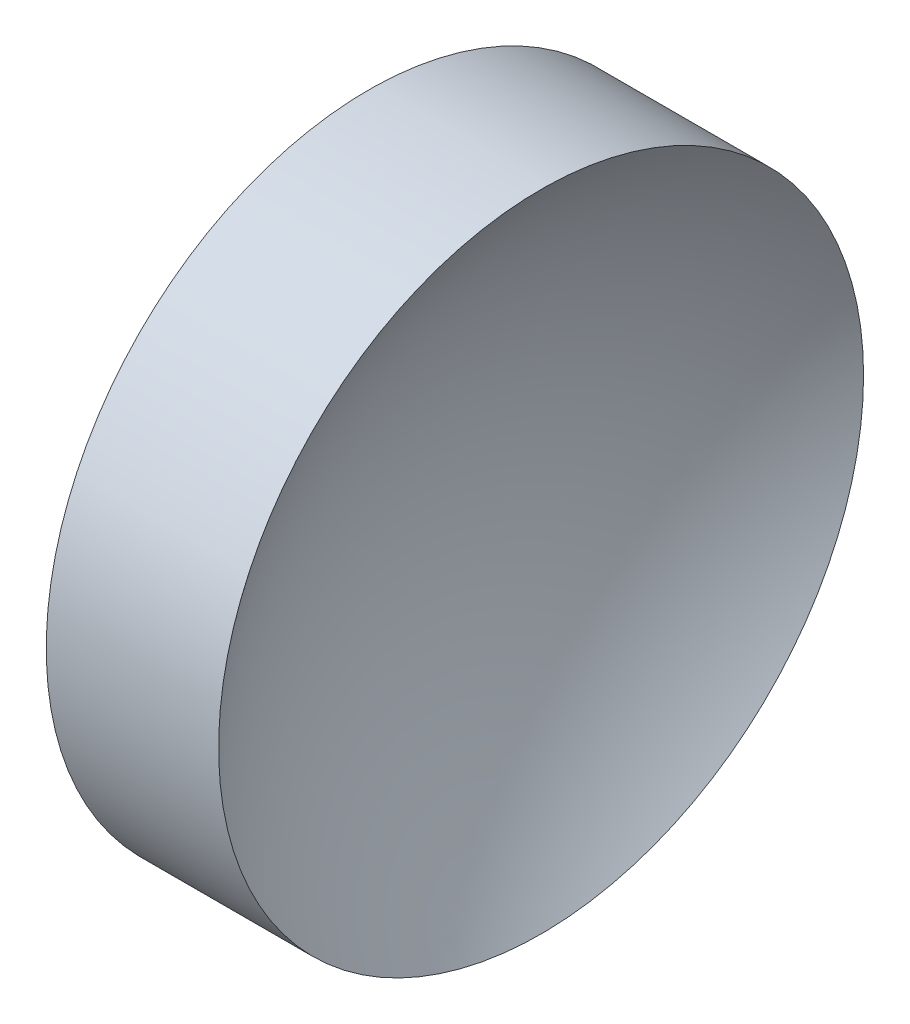
from build123d import *


with BuildPart() as part:
    # 草图1 → 旋转1 (revolve)
    with BuildSketch(Plane.XY, mode=Mode.PRIVATE) as revolve_1_sk:
        with BuildLine():
            Line((44.319152693, 26.089041149), (44.319152693, 34.089041149))
            Line((44.319152693, 34.089041149), (48.595138815, 34.089041149))
            ThreePointArc((48.595138815, 34.089041149), (46.532583909, 30.323115392), (45.819180195, 26.089041149))
            Line((45.819180195, 26.089041149), (44.319152693, 26.089041149))
        make_face()
    revolve(revolve_1_sk.sketch.rotate(Axis((45.819180195, 26.089041149, 0), (-1, 0, 0)), 90), axis=Axis((45.819180195, 26.089041149, 0), (-1, 0, 0)))  # turned: the seam where the file's is


solid = part.part
